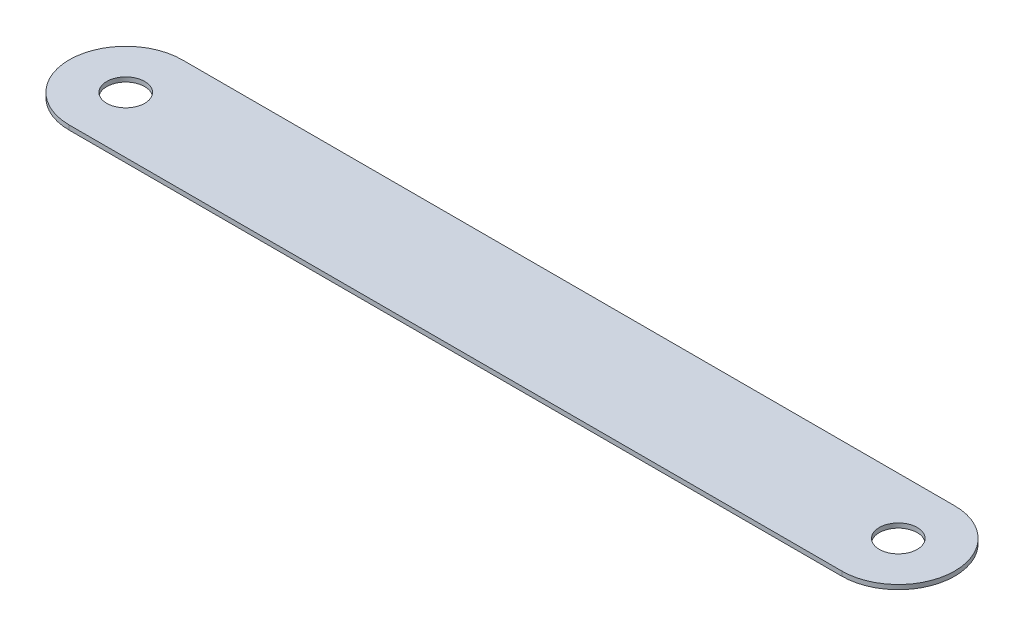
from build123d import *

# Parameters (mm, degrees)
SKETCH_1_R      = 2.1
EXTRUDE_1_DEPTH = 0.5


with BuildPart() as part:
    # 草圖1 → 填料-伸長1 (new body)
    with BuildSketch(Plane(origin=(0, 0, 0), x_dir=(1, 0, 0), z_dir=(0, 1, 0))):
        with BuildLine():
            Line((-42.75, 6.25), (42.75, 6.25))
            ThreePointArc((42.75, 6.25), (49, 0), (42.75, -6.25))
            Line((42.75, -6.25), (-42.75, -6.25))
            ThreePointArc((-42.75, -6.25), (-49, 0), (-42.75, 6.25))
        make_face()
        with Locations((-42.75, 0)):
            Circle(SKETCH_1_R, mode=Mode.SUBTRACT)
        with Locations((42.75, 0)):
            Circle(SKETCH_1_R, mode=Mode.SUBTRACT)
    extrude(amount=EXTRUDE_1_DEPTH)


solid = part.part
